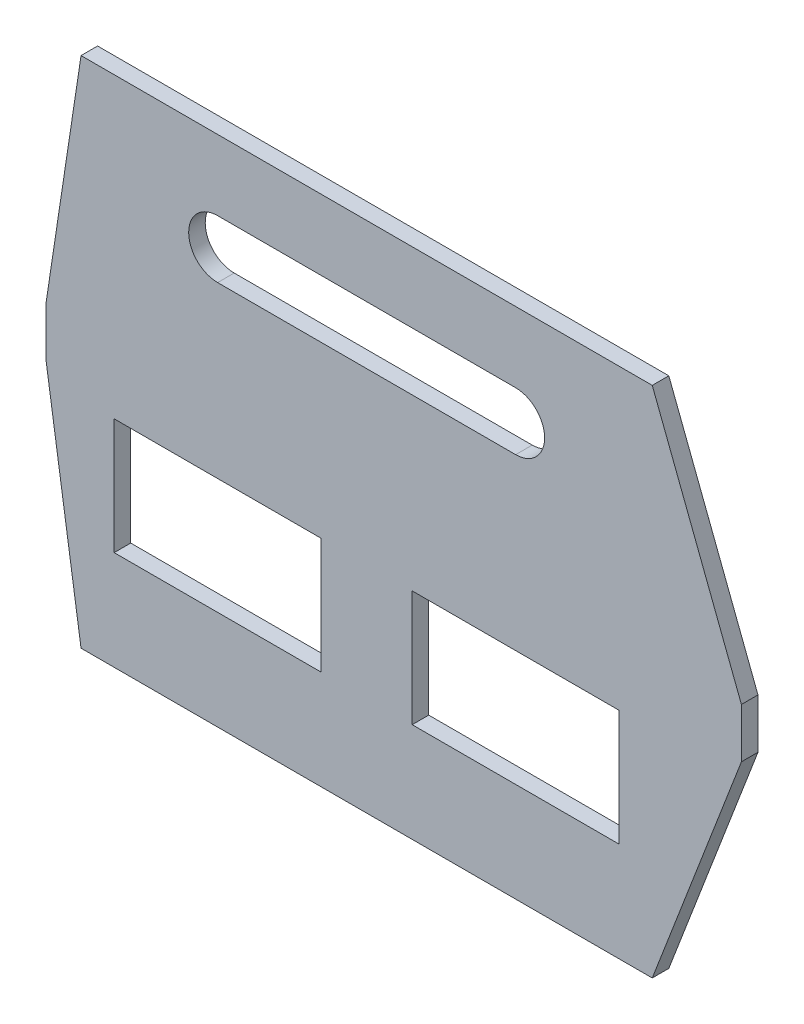
from build123d import *

# Parameters (mm, degrees)
SKETCH4_W           = 125
SKETCH4_H           = 70
BOSS_EXTRUDE1_DEPTH = 10


with BuildPart() as part:
    # Sketch4 → Boss-Extrude1 (new body)
    with BuildSketch(Plane.XY):
        Polygon((0, 0), (-345, 0), (-366.148351929, 140), (-366.148351929, 170), (-345, 310), (0, 310), (53.851648071, 170), (53.851648071, 140), align=None)
        with BuildLine():
            Line((-262.5, 267.5), (-82.5, 267.5))
            ThreePointArc((-82.5, 267.5), (-65, 250), (-82.5, 232.5))
            Line((-82.5, 232.5), (-262.5, 232.5))
            ThreePointArc((-262.5, 232.5), (-280, 250), (-262.5, 267.5))
        make_face(mode=Mode.SUBTRACT)
        with Locations((-262.5, 95)):
            Rectangle(SKETCH4_W, SKETCH4_H, mode=Mode.SUBTRACT)
        with Locations((-82.5, 95)):
            Rectangle(SKETCH4_W, SKETCH4_H, mode=Mode.SUBTRACT)
    extrude(amount=BOSS_EXTRUDE1_DEPTH)


solid = part.part
